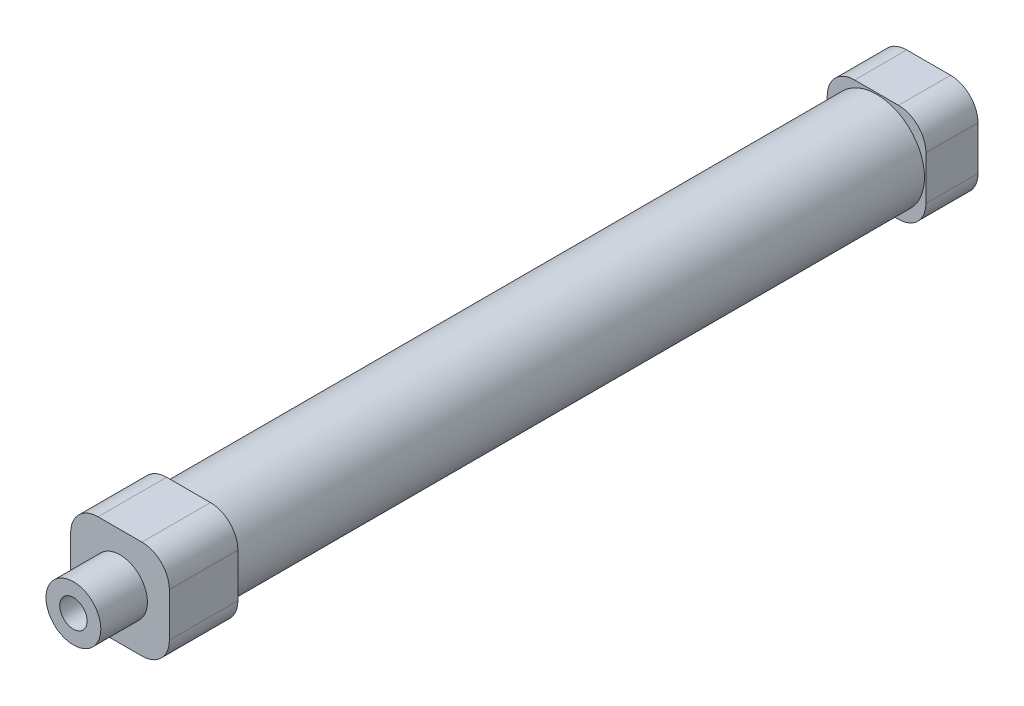
from build123d import *

# Parameters (mm, degrees)
SKETCH_1_W          = 18
SKETCH_1_H          = 18
EXTRUDE_1_DEPTH     = 9.5
SKETCH_2_R          = 8.75
EXTRUDE_2_DEPTH     = 125.5
SKETCH_3_W          = 18
SKETCH_3_H          = 18
EXTRUDE_3_DEPTH     = 12.5
SKETCH_4_R          = 5
EXTRUDE_4_DEPTH     = 8.5
SKETCH_5_R          = 2.5
CUT_EXTRUDE_1_DEPTH = 155
FILLET_1_R          = 5
CUT_EXTRUDE_2_REACH = 20
SKETCH_6_R          = 2.5


with BuildPart() as part:
    # 草图1 → 凸台-拉伸1 (new body)
    with BuildSketch(Plane.XY):
        Rectangle(SKETCH_1_W, SKETCH_1_H)
    extrude(amount=EXTRUDE_1_DEPTH)

    # 草图2 → 凸台-拉伸2 (add)
    with BuildSketch(Plane.XY.offset(9.5)):
        Circle(SKETCH_2_R)
    extrude(amount=EXTRUDE_2_DEPTH)

    # 草图3 → 凸台-拉伸3 (add)
    with BuildSketch(Plane.XY.offset(135)):
        Rectangle(SKETCH_3_W, SKETCH_3_H)
    extrude(amount=EXTRUDE_3_DEPTH)

    # 草图4 → 凸台-拉伸4 (add)
    with BuildSketch(Plane.XY.offset(147.5)):
        Circle(SKETCH_4_R)
    extrude(amount=EXTRUDE_4_DEPTH)

    # 草图5 → 切除-拉伸1 (cut)
    with BuildSketch(Plane.XY.offset(156)):
        Circle(SKETCH_5_R)
    extrude(amount=-CUT_EXTRUDE_1_DEPTH, mode=Mode.SUBTRACT)

    # 圆角1
    fillet_1_edges = [part.edges().sort_by_distance(p)[0] for p in [
        (9, -9, 141.25),
        (9, 9, 141.25),
        (-9, 9, 141.25),
        (-9, -9, 141.25),
        (9, -9, 4.75),
        (-9, -9, 4.75),
        (-9, 9, 4.75),
        (9, 9, 4.75),
    ]]
    fillet(fillet_1_edges, radius=FILLET_1_R)

    # 草图6 → 切除-拉伸2 (cut, up to next)
    with BuildSketch(Plane.XZ.offset(9), mode=Mode.PRIVATE) as cut_extrude_2_sk1:
        with Locations((0, 4.75)):
            Circle(SKETCH_6_R)
    cut_extrude_2_tool1 = extrude(cut_extrude_2_sk1.sketch, amount=-CUT_EXTRUDE_2_REACH, mode=Mode.PRIVATE) & part.part
    add(cut_extrude_2_tool1.solids().sort_by_distance((0, -9, 4.75))[0], mode=Mode.SUBTRACT)
    # 草图6 → 切除-拉伸2 (cut, up to next)
    with BuildSketch(Plane.XZ.offset(9), mode=Mode.PRIVATE) as cut_extrude_2_sk2:
        with Locations((0, 139.75)):
            Circle(SKETCH_6_R)
    cut_extrude_2_tool2 = extrude(cut_extrude_2_sk2.sketch, amount=-CUT_EXTRUDE_2_REACH, mode=Mode.PRIVATE) & part.part
    add(cut_extrude_2_tool2.solids().sort_by_distance((0, -9, 139.75))[0], mode=Mode.SUBTRACT)


solid = part.part
